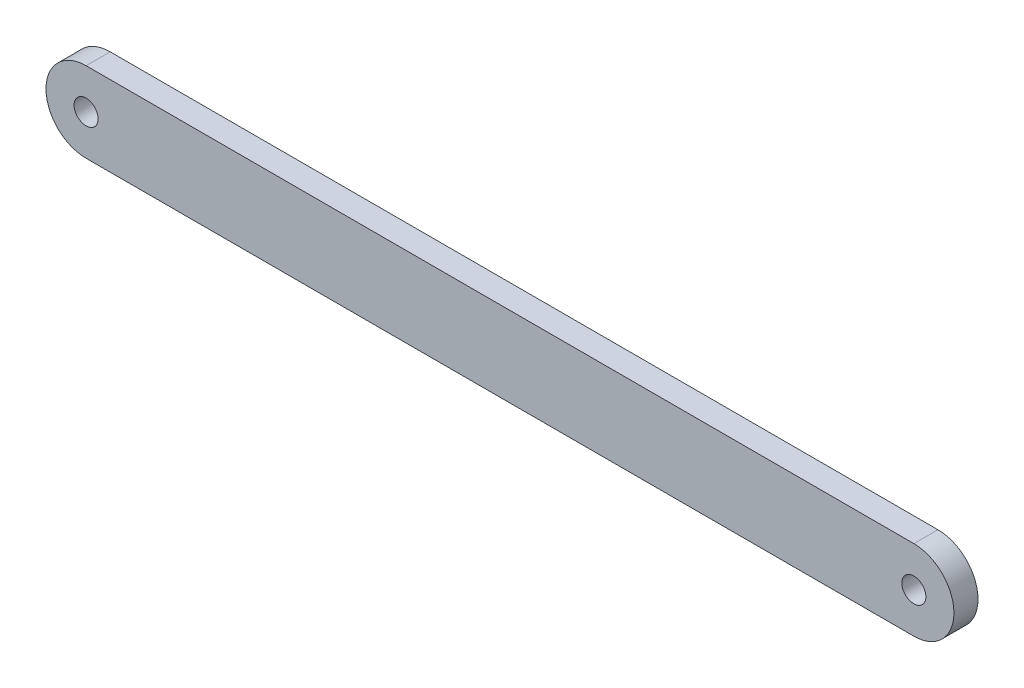
from build123d import *

# Parameters (mm, degrees)
SKETCH_1_R      = 0.75
EXTRUDE_1_DEPTH = 0.75


with BuildPart() as part:
    # 草圖1 → 填料-伸長1 (new body, symmetric)
    with BuildSketch(Plane.XY):
        with BuildLine():
            Line((-25.805, 2.5), (25.805, 2.5))
            ThreePointArc((25.805, 2.5), (28.305, 0), (25.805, -2.5))
            Line((25.805, -2.5), (-25.805, -2.5))
            ThreePointArc((-25.805, -2.5), (-28.305, 0), (-25.805, 2.5))
        make_face()
        with Locations((25.805, 0)):
            Circle(SKETCH_1_R, mode=Mode.SUBTRACT)
        with Locations((-25.805, 0)):
            Circle(SKETCH_1_R, mode=Mode.SUBTRACT)
    extrude(amount=EXTRUDE_1_DEPTH, both=True)


solid = part.part
